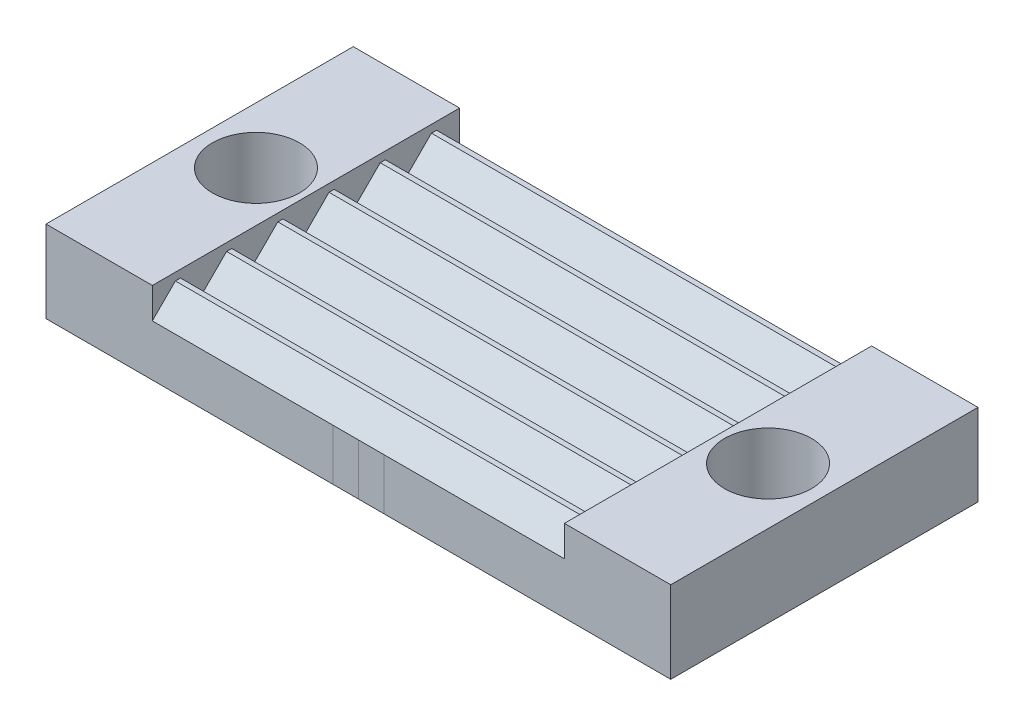
from build123d import *

# Parameters (mm, degrees)
CROQUIS1_R              = 1.7
SALIENTE_EXTRUIR1_DEPTH = 2
SALIENTE_EXTRUIR2_START = 4.796684
SALIENTE_EXTRUIR2_DEPTH = 16.093368
MATRIZL1_COUNT          = 6
MATRIZL1_PITCH          = 2
SKETCH1_W               = 2
SKETCH1_H               = 2
CUT_EXTRUDE1_DEPTH      = 0.1
SKETCH1_3_W             = 1
SKETCH1_3_H             = 2
BOSS_EXTRUDE1_DEPTH     = 0.1
SKETCH1_4_W             = 1
SKETCH1_4_H             = 2
BOSS_EXTRUDE2_DEPTH     = 0.1
BOSS_EXTRUDE3_START     = 2
CROQUIS1_4_R            = 1.7
BOSS_EXTRUDE3_DEPTH     = 1.2
BOSS_EXTRUDE4_DEPTH     = 3.2


with BuildPart() as part:
    # Croquis1 → Saliente-Extruir1 (new body)
    with BuildSketch(Plane(origin=(0, 0, 0), x_dir=(1, 0, 0), z_dir=(0, 1, 0))):
        Polygon((-8.046684223, -2.46171515), (-8.046684223, 2.46171515), (-8.046684223, 6), (8.046684223, 6), (8.046684223, 2.46171515), (8.046684223, -2.46171515), (8.046684223, -6), (-8.046684223, -6), align=None)
        with BuildLine():
            Line((8.046684223, -2.46171515), (8.046684223, 2.46171515))
            ThreePointArc((8.046684223, 2.46171515), (8.827888747, 2.181898598), (9.657649034, 2.173199442))
            ThreePointArc((9.657649034, 2.173199442), (12.2, 0), (9.657649034, -2.173199442))
            ThreePointArc((9.657649034, -2.173199442), (8.827888747, -2.181898598), (8.046684223, -2.46171515))
        make_face()
        with Locations((10, 0)):
            Circle(CROQUIS1_R, mode=Mode.SUBTRACT)
        with BuildLine():
            ThreePointArc((-9.657649034, -2.173199442), (-12.2, 0), (-9.657649034, 2.173199442))
            ThreePointArc((-9.657649034, 2.173199442), (-8.827888747, 2.181898598), (-8.046684223, 2.46171515))
            Line((-8.046684223, 2.46171515), (-8.046684223, -2.46171515))
            ThreePointArc((-8.046684223, -2.46171515), (-8.827888747, -2.181898598), (-9.657649034, -2.173199442))
        make_face()
        with Locations((-10, 0)):
            Circle(CROQUIS1_R, mode=Mode.SUBTRACT)
    extrude(amount=SALIENTE_EXTRUIR1_DEPTH)

    # Croquis4 → Saliente-Extruir2 (add)
    with BuildSketch(Plane(origin=(3.25, 0, 0), x_dir=(0, 0, -1), z_dir=(1, 0, 0)).offset(SALIENTE_EXTRUIR2_START)):
        Polygon((-6, 2), (-4, 2), (-4.9, 2.9), (-5.1, 2.9), align=None)
    saliente_extruir2 = extrude(amount=-SALIENTE_EXTRUIR2_DEPTH)

    # MatrizL1: Saliente-Extruir2 ×6
    with Locations(*[(0, 0, -i * MATRIZL1_PITCH) for i in range(1, MATRIZL1_COUNT)]):
        add(saliente_extruir2)

    # Sketch1 → Cut-Extrude1 (cut)
    with BuildSketch(Plane.XY.offset(6)):
        with Locations((0, 1)):
            Rectangle(SKETCH1_W, SKETCH1_H)
    extrude(amount=-CUT_EXTRUDE1_DEPTH, mode=Mode.SUBTRACT)

    # Croquis1_4 → Boss-Extrude3 (add)
    with BuildSketch(Plane(origin=(0, 0, 0), x_dir=(1, 0, 0), z_dir=(0, 1, 0)).offset(BOSS_EXTRUDE3_START)):
        with BuildLine():
            ThreePointArc((-9.657649034, -2.173199442), (-12.2, 0), (-9.657649034, 2.173199442))
            ThreePointArc((-9.657649034, 2.173199442), (-8.827888747, 2.181898598), (-8.046684223, 2.46171515))
            Line((-8.046684223, 2.46171515), (-8.046684223, -2.46171515))
            ThreePointArc((-8.046684223, -2.46171515), (-8.827888747, -2.181898598), (-9.657649034, -2.173199442))
        make_face()
        with Locations((-10, 0)):
            Circle(CROQUIS1_4_R, mode=Mode.SUBTRACT)
        with BuildLine():
            Line((8.046684223, -2.46171515), (8.046684223, 2.46171515))
            ThreePointArc((8.046684223, 2.46171515), (8.827888747, 2.181898598), (9.657649034, 2.173199442))
            ThreePointArc((9.657649034, 2.173199442), (12.2, 0), (9.657649034, -2.173199442))
            ThreePointArc((9.657649034, -2.173199442), (8.827888747, -2.181898598), (8.046684223, -2.46171515))
        make_face()
        with Locations((10, 0)):
            Circle(CROQUIS1_4_R, mode=Mode.SUBTRACT)
    extrude(amount=BOSS_EXTRUDE3_DEPTH)

    # Croquis1_6 → Boss-Extrude4 (add)
    with BuildSketch(Plane(origin=(0, 0, 0), x_dir=(1, 0, 0), z_dir=(0, 1, 0))):
        with BuildLine():
            ThreePointArc((9.657649034, -2.173199442), (8.827888747, -2.181898598), (8.046684223, -2.46171515))
            Line((8.046684223, -2.46171515), (8.046684223, -6))
            Line((8.046684223, -6), (12.2, -6))
            Line((12.2, -6), (12.2, 0))
            ThreePointArc((12.2, 0), (11.429480303, -1.672299633), (9.657649034, -2.173199442))
        make_face()
        with BuildLine():
            Line((12.2, 6), (8.046684223, 6))
            Line((8.046684223, 6), (8.046684223, 2.46171515))
            ThreePointArc((8.046684223, 2.46171515), (8.827888747, 2.181898598), (9.657649034, 2.173199442))
            ThreePointArc((9.657649034, 2.173199442), (11.429480303, 1.672299633), (12.2, 0))
            Line((12.2, 0), (12.2, 6))
        make_face()
        with BuildLine():
            Line((-8.046684223, -6), (-8.046684223, -2.46171515))
            ThreePointArc((-8.046684223, -2.46171515), (-8.827888747, -2.181898598), (-9.657649034, -2.173199442))
            ThreePointArc((-9.657649034, -2.173199442), (-11.429480303, -1.672299633), (-12.2, 0))
            Line((-12.2, 0), (-12.2, -6))
            Line((-12.2, -6), (-8.046684223, -6))
        make_face()
        with BuildLine():
            Line((-8.046684223, 2.46171515), (-8.046684223, 6))
            Line((-8.046684223, 6), (-12.2, 6))
            Line((-12.2, 6), (-12.2, 0))
            ThreePointArc((-12.2, 0), (-11.429480303, 1.672299633), (-9.657649034, 2.173199442))
            ThreePointArc((-9.657649034, 2.173199442), (-8.827888747, 2.181898598), (-8.046684223, 2.46171515))
        make_face()
    extrude(amount=BOSS_EXTRUDE4_DEPTH)


with BuildPart() as body_2:
    # Sketch1_3 → Boss-Extrude1 (new body)
    with BuildSketch(Plane.XY.offset(6)):
        with Locations((0.5, 1)):
            Rectangle(SKETCH1_3_W, SKETCH1_3_H)
    extrude(amount=-BOSS_EXTRUDE1_DEPTH)


with BuildPart() as body_3:
    # Sketch1_4 → Boss-Extrude2 (new body)
    with BuildSketch(Plane.XY.offset(6)):
        with Locations((-0.5, 1)):
            Rectangle(SKETCH1_4_W, SKETCH1_4_H)
    extrude(amount=-BOSS_EXTRUDE2_DEPTH)


solid = Compound([part.part, body_2.part, body_3.part])
